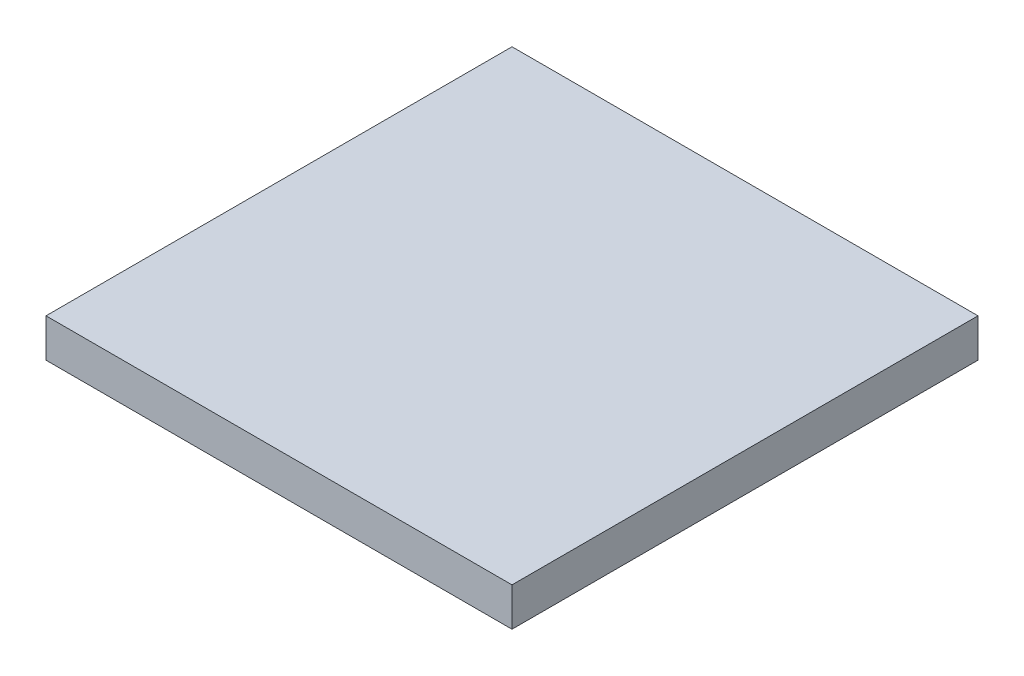
from build123d import *

# Parameters (mm, degrees)
SKETCH1_W           = 40
SKETCH1_H           = 40
BOSS_EXTRUDE1_DEPTH = 3.3


with BuildPart() as part:
    # Sketch1 → Boss-Extrude1 (new body)
    with BuildSketch(Plane(origin=(0, 0, 0), x_dir=(1, 0, 0), z_dir=(0, 1, 0))):
        Rectangle(SKETCH1_W, SKETCH1_H)
    extrude(amount=BOSS_EXTRUDE1_DEPTH)


solid = part.part
